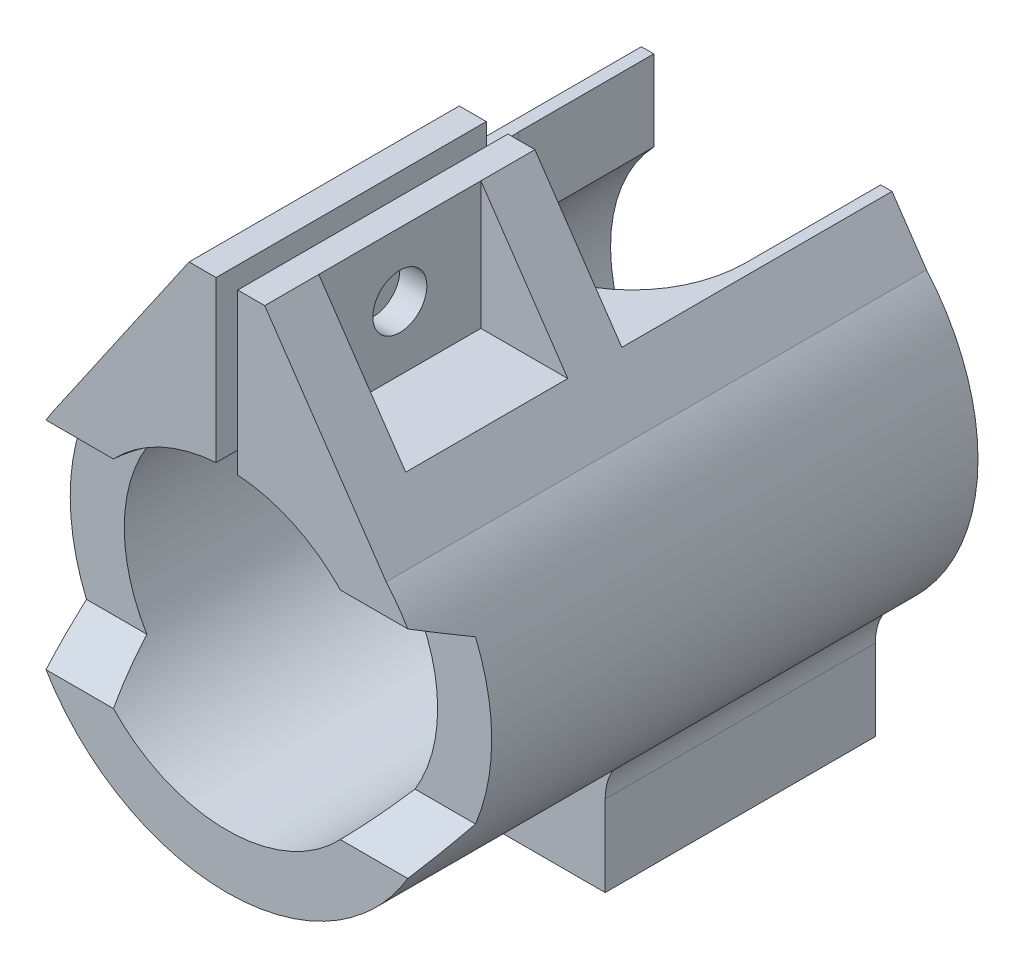
from build123d import *

# Parameters (mm, degrees)
BOSS_EXTRUDE1_DEPTH            = 50
SKETCH4_W                      = 15
SKETCH4_H                      = 11.826160891
CUT_EXTRUDE3_DEPTH             = 17
SKETCH5_R                      = 2.5
CUT_EXTRUDE4_DEPTH             = 17
CUT_EXTRUDE4_DEPTH_BACK        = 24
SKETCH9_W                      = 25
SKETCH9_H                      = 11.826160891
CUT_EXTRUDE8_DEPTH             = 17
CUT_EXTRUDE8_DEPTH_BACK        = 24
CUT_EXTRUDE9_REACH             = 44
CUT_EXTRUDE9_DIRECTION_2_REACH = 16.792
CUT_EXTRUDE10_DEPTH            = 13
CUT_EXTRUDE10_DEPTH_BACK       = 13.5000001
CUT_EXTRUDE11_DEPTH            = 20.5
CUT_EXTRUDE11_DEPTH_BACK       = 20.5
CUT_EXTRUDE15_REACH            = 58.792
SKETCH14_R                     = 3.375
BOSS_EXTRUDE2_DEPTH            = 2.5
CUT_EXTRUDE17_DEPTH            = 25
SKETCH16_W                     = 20
SKETCH16_H                     = 25
CUT_EXTRUDE18_DEPTH            = 0.5


with BuildPart() as part:
    # Sketch1 → Boss-Extrude1 (new body)
    with BuildSketch(Plane.XY):
        with BuildLine():
            Line((3.5, 29.291637032), (1, 29.291637032))
            Line((1, 29.291637032), (1, 14.465476141))
            ThreePointArc((1, 14.465476141), (0, -14.5), (-1, 14.465476141))
            Line((-1, 14.465476141), (-1, 29.291637032))
            Line((-1, 29.291637032), (-3.5, 29.291637032))
            Line((-3.5, 29.291637032), (-16.058186159, 11.06275993))
            ThreePointArc((-16.058186159, 11.06275993), (-19.250030671, -3.112285199), (-11.754006256, -15.559348859))
            ThreePointArc((-11.754006256, -15.559348859), (-6.198495674, -18.488608692), (0, -19.5))
            ThreePointArc((0, -19.5), (6.13886546, -18.508493479), (11.653451419, -15.634803166))
            ThreePointArc((11.653451419, -15.634803166), (12.039474024, -15.299956246), (12.455712019, -15.003507527))
            ThreePointArc((12.455712019, -15.003507527), (17.651294349, -8.287448812), (19.5, 0))
            ThreePointArc((19.5, 0), (18.269595128, 6.817029694), (14.733651913, 12.773781793))
            Line((14.733651913, 12.773781793), (3.5, 29.291637032))
        make_face()
        with BuildLine():
            ThreePointArc((10, -19.5), (10.430719001, -17.397998087), (11.653451419, -15.634803166))
            ThreePointArc((11.653451419, -15.634803166), (6.13886546, -18.508493479), (0, -19.5))
            ThreePointArc((0, -19.5), (-6.198495674, -18.488608692), (-11.754006256, -15.559348859))
            ThreePointArc((-11.754006256, -15.559348859), (-10.458303194, -17.343308705), (-10, -19.5))
            Line((-10, -19.5), (-10, -27.5))
            Line((-10, -27.5), (10, -27.5))
            Line((10, -27.5), (10, -19.5))
        make_face()
    extrude(amount=-BOSS_EXTRUDE1_DEPTH)

    # Sketch4 → Cut-Extrude3 (cut, through all)
    with BuildSketch(Plane(origin=(3.5, 0, 0), x_dir=(0, 0, -1), z_dir=(1, 0, 0))):
        with Locations((12.5, 23.378556587)):
            Rectangle(SKETCH4_W, SKETCH4_H)
    cut_extrude3 = extrude(amount=CUT_EXTRUDE3_DEPTH, mode=Mode.SUBTRACT)

    # Mirror1: Cut-Extrude3 across plane
    add(cut_extrude3.mirror(Plane(origin=(0, 0, 0), x_dir=(0, 0, 1), z_dir=(1, 0, 0))), mode=Mode.SUBTRACT)

    # Sketch5 → Cut-Extrude4 (cut, two sides)
    with BuildSketch(Plane(origin=(3.5, 0, 0), x_dir=(0, 0, -1), z_dir=(1, 0, 0))) as cut_extrude4_sk:
        with Locations((12.5, 23.378556587)):
            Circle(SKETCH5_R)
    extrude(amount=CUT_EXTRUDE4_DEPTH, mode=Mode.SUBTRACT)
    extrude(cut_extrude4_sk.sketch, amount=-CUT_EXTRUDE4_DEPTH_BACK, mode=Mode.SUBTRACT)

    # Sketch9 → Cut-Extrude8 (cut, two sides)
    with BuildSketch(Plane(origin=(3.5, 0, 0), x_dir=(0, 0, -1), z_dir=(1, 0, 0))) as cut_extrude8_sk:
        with Locations((37.5, 23.378556587)):
            Rectangle(SKETCH9_W, SKETCH9_H)
    extrude(amount=CUT_EXTRUDE8_DEPTH, mode=Mode.SUBTRACT)
    extrude(cut_extrude8_sk.sketch, amount=-CUT_EXTRUDE8_DEPTH_BACK, mode=Mode.SUBTRACT)

    # Sketch8 → Cut-Extrude9 (cut, up to next)
    with BuildSketch(Plane(origin=(0, 14.5, 0), x_dir=(1, 0, 0), z_dir=(0, 1, 0)), mode=Mode.PRIVATE) as cut_extrude9_sk1:
        with BuildLine():
            Line((-10.5, 37.5), (-10.5, 50))
            Line((-10.5, 50), (-1, 50))
            Line((-1, 50), (-1, 27.04772752))
            ThreePointArc((-1, 27.04772752), (-7.770135134, 30.437776554), (-10.5, 37.5))
        make_face()
    cut_extrude9_tool1 = extrude(cut_extrude9_sk1.sketch, amount=-CUT_EXTRUDE9_REACH, mode=Mode.PRIVATE) & part.part
    add(cut_extrude9_tool1.solids().sort_by_distance((-5.457616, 14.5, -39.610639))[0], mode=Mode.SUBTRACT)
    # Sketch8 → Cut-Extrude9 (cut, up to next)
    with BuildSketch(Plane(origin=(0, 14.5, 0), x_dir=(1, 0, 0), z_dir=(0, 1, 0)), mode=Mode.PRIVATE) as cut_extrude9_sk2:
        with BuildLine():
            Line((10.5, 50), (10.5, 37.5))
            ThreePointArc((10.5, 37.5), (7.770135134, 30.437776554), (1, 27.04772752))
            Line((1, 27.04772752), (1, 50))
            Line((1, 50), (10.5, 50))
        make_face()
    cut_extrude9_tool2 = extrude(cut_extrude9_sk2.sketch, amount=-CUT_EXTRUDE9_REACH, mode=Mode.PRIVATE) & part.part
    add(cut_extrude9_tool2.solids().sort_by_distance((5.457616, 14.5, -39.610639))[0], mode=Mode.SUBTRACT)

    # Sketch8 → Cut-Extrude9 direction 2 (cut, up to next)
    with BuildSketch(Plane(origin=(0, 14.5, 0), x_dir=(1, 0, 0), z_dir=(0, 1, 0)), mode=Mode.PRIVATE) as cut_extrude9_direction_2_sk1:
        with BuildLine():
            Line((-10.5, 37.5), (-10.5, 50))
            Line((-10.5, 50), (-1, 50))
            Line((-1, 50), (-1, 27.04772752))
            ThreePointArc((-1, 27.04772752), (-7.770135134, 30.437776554), (-10.5, 37.5))
        make_face()
    cut_extrude9_direction_2_tool1 = extrude(cut_extrude9_direction_2_sk1.sketch, amount=CUT_EXTRUDE9_DIRECTION_2_REACH, mode=Mode.PRIVATE) & part.part
    add(cut_extrude9_direction_2_tool1.solids().sort_by_distance((-5.457616, 14.5, -39.610639))[0], mode=Mode.SUBTRACT)
    # Sketch8 → Cut-Extrude9 direction 2 (cut, up to next)
    with BuildSketch(Plane(origin=(0, 14.5, 0), x_dir=(1, 0, 0), z_dir=(0, 1, 0)), mode=Mode.PRIVATE) as cut_extrude9_direction_2_sk2:
        with BuildLine():
            Line((10.5, 50), (10.5, 37.5))
            ThreePointArc((10.5, 37.5), (7.770135134, 30.437776554), (1, 27.04772752))
            Line((1, 27.04772752), (1, 50))
            Line((1, 50), (10.5, 50))
        make_face()
    cut_extrude9_direction_2_tool2 = extrude(cut_extrude9_direction_2_sk2.sketch, amount=CUT_EXTRUDE9_DIRECTION_2_REACH, mode=Mode.PRIVATE) & part.part
    add(cut_extrude9_direction_2_tool2.solids().sort_by_distance((5.457616, 14.5, -39.610639))[0], mode=Mode.SUBTRACT)

    # Sketch10 → Cut-Extrude10 (cut, two sides)
    with BuildSketch(Plane.XY.offset(-37.5)) as cut_extrude10_sk:
        with BuildLine():
            Line((-7, -12.698425099), (7, -12.698425099))
            Line((7, -12.698425099), (7, -14.941552797))
            ThreePointArc((7, -14.941552797), (0, -16.5), (-7, -14.941552797))
            Line((-7, -14.941552797), (-7, -12.698425099))
        make_face()
    extrude(amount=CUT_EXTRUDE10_DEPTH, mode=Mode.SUBTRACT)
    extrude(cut_extrude10_sk.sketch, amount=-CUT_EXTRUDE10_DEPTH_BACK, mode=Mode.SUBTRACT)

    # Sketch11 → Cut-Extrude11 (cut, two sides)
    with BuildSketch(Plane(origin=(0, 0, 0), x_dir=(0, 0, -1), z_dir=(1, 0, 0))) as cut_extrude11_sk:
        Polygon((5, -7.5), (0, -10), (0, 10), (5, 7.5), align=None)
    extrude(amount=CUT_EXTRUDE11_DEPTH, mode=Mode.SUBTRACT)
    extrude(cut_extrude11_sk.sketch, amount=-CUT_EXTRUDE11_DEPTH_BACK, mode=Mode.SUBTRACT)

    # Sketch13 → Cut-Extrude15 (cut, up to next)
    with BuildSketch(Plane.XZ.offset(27.5), mode=Mode.PRIVATE) as cut_extrude15_sk1:
        Polygon((0, -31.084195134), (-5.55625, -34.292097567), (-5.55625, -40.707902433), (0, -43.915804866), (5.55625, -40.707902433), (5.55625, -34.292097567), align=None)
    cut_extrude15_tool1 = extrude(cut_extrude15_sk1.sketch, amount=-CUT_EXTRUDE15_REACH, mode=Mode.PRIVATE) & part.part
    add(cut_extrude15_tool1.solids().sort_by_distance((0, -27.5, -37.5))[0], mode=Mode.SUBTRACT)

    # Sketch14 → Boss-Extrude2 (add)
    with BuildSketch(Plane.XZ.offset(27.5)):
        Polygon((5.55625, -40.707902433), (5.55625, -34.292097567), (0, -31.084195134), (-5.55625, -34.292097567), (-5.55625, -40.707902433), (0, -43.915804866), align=None)
        with Locations((0, -37.5)):
            Circle(SKETCH14_R, mode=Mode.SUBTRACT)
    extrude(amount=-BOSS_EXTRUDE2_DEPTH)

    # Sketch15 → Cut-Extrude17 (cut)
    with BuildSketch(Plane.XY):
        with BuildLine():
            Line((-19.5, 0), (-19.5, -27.5))
            Line((-19.5, -27.5), (19.5, -27.5))
            Line((19.5, -27.5), (19.5, 0))
            ThreePointArc((19.5, 0), (0, -19.5), (-19.5, 0))
        make_face()
    extrude(amount=-CUT_EXTRUDE17_DEPTH, mode=Mode.SUBTRACT)

    # Sketch16 → Cut-Extrude18 (cut)
    with BuildSketch(Plane.XZ.offset(27.5)):
        with Locations((0, -37.5)):
            Rectangle(SKETCH16_W, SKETCH16_H)
    extrude(amount=-CUT_EXTRUDE18_DEPTH, mode=Mode.SUBTRACT)


solid = part.part
